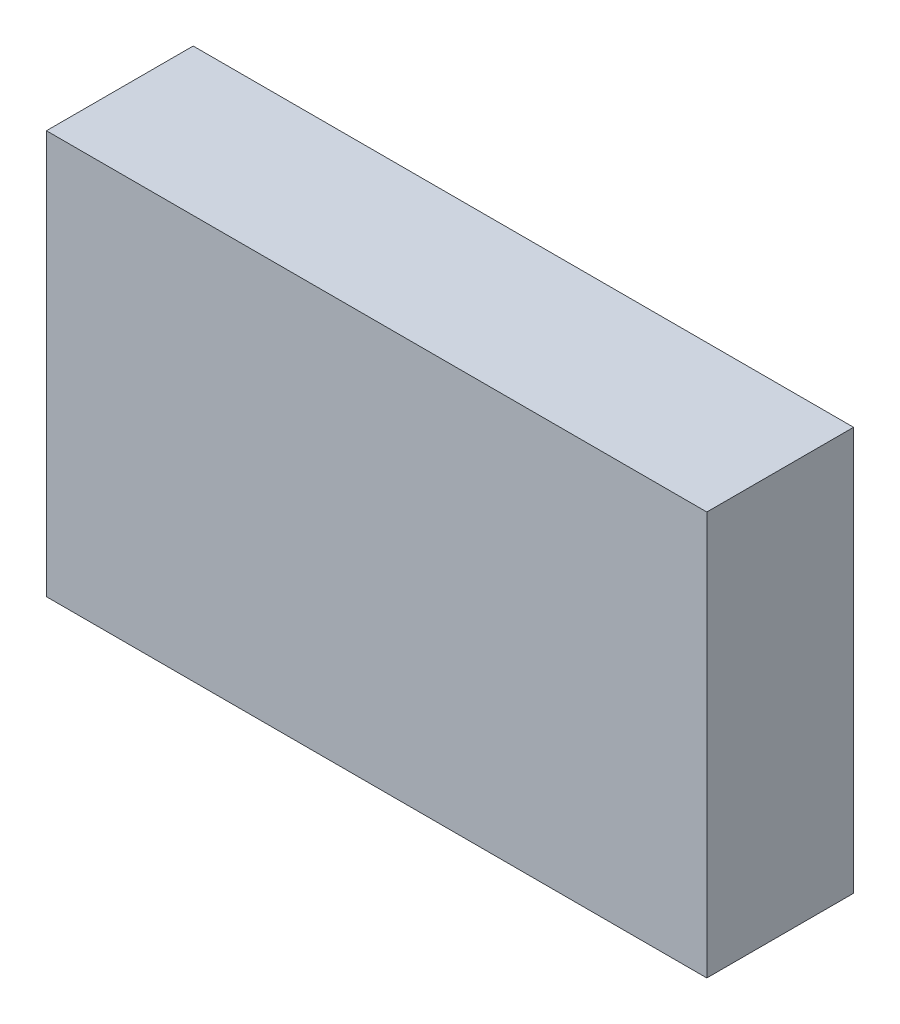
from build123d import *

# Parameters (mm, degrees)
SKETCH_1_W      = 90
SKETCH_1_H      = 55
EXTRUDE_1_DEPTH = 20


with BuildPart() as part:
    # Эскиз1 → Бобышка-Вытянуть1 (new body)
    with BuildSketch(Plane.XY):
        with Locations((-45, 27.5)):
            Rectangle(SKETCH_1_W, SKETCH_1_H)
    extrude(amount=EXTRUDE_1_DEPTH)


solid = part.part
